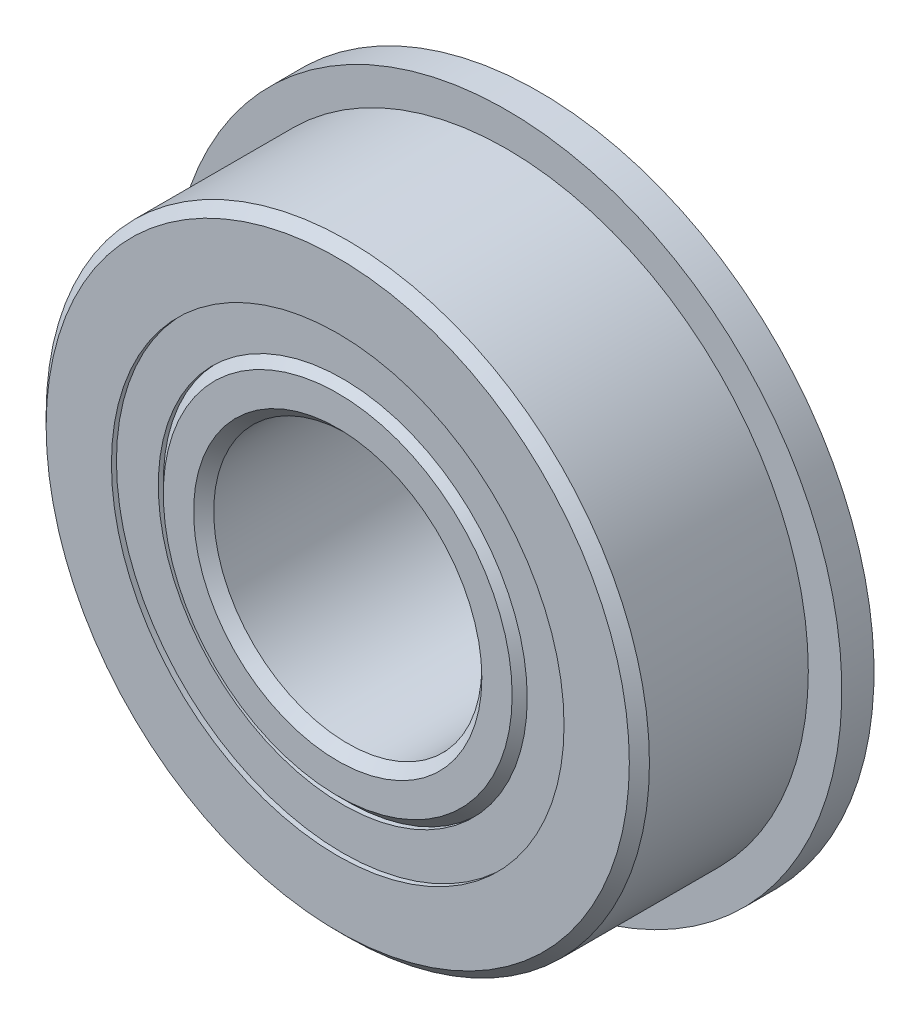
from build123d import *

# Parameters (mm, degrees)
SKETCH6_W          = 1.524
SKETCH6_H          = 5.1562
CIRPATTERN1_COUNT  = 12
SKETCH5_W          = 2.743836812
SKETCH5_H          = 1.9812
CUT_EXTRUDE1_DEPTH = 0.00254


with BuildPart() as part:
    # Sketch1 → Revolve1 (revolve)
    with BuildSketch(Plane(origin=(0, 0, 0), x_dir=(0, 0, -1), z_dir=(1, 0, 0))):
        with BuildLine():
            Line((4.28625, 14.2875), (-4.28625, 14.2875))
            Line((-4.28625, 14.2875), (-4.7625, 13.81125))
            Line((-4.7625, 13.81125), (-4.7625, 10.7188))
            Line((-4.7625, 10.7188), (-2.347405282, 10.7188))
            ThreePointArc((-2.347405282, 10.7188), (0, 12.7), (2.347405282, 10.7188))
            Line((2.347405282, 10.7188), (4.7625, 10.7188))
            Line((4.7625, 10.7188), (4.7625, 13.81125))
            Line((4.7625, 13.81125), (4.28625, 14.2875))
        make_face()
    revolve(axis=Axis((0, 0, 4.7625), (0, 0, -1)))

    # Sketch6 → Revolve6 (revolve)
    with BuildSketch(Plane(origin=(0, 0, 0), x_dir=(0, 0, -1), z_dir=(1, 0, 0))):
        with Locations((4.0005, 13.2969)):
            Rectangle(SKETCH6_W, SKETCH6_H)
    revolve(axis=Axis((0, 0, -4.7625), (0, 0, 1)))

    # Sketch7 → Cut-Extrude1 (cut)
    with BuildSketch(Plane(origin=(0, 0, -4.7625), x_dir=(-1, 0, 0), z_dir=(0, 0, -1))):
        with BuildLine():
            ThreePointArc((-9.493299855, 12.723713407), (-9.643749817, 12.610064015), (-9.792839353, 12.494635745))
            Line((-9.792839353, 12.494635745), (-6.612125131, 8.436378055))
            ThreePointArc((-6.612125131, 8.436378055), (-6.462690611, 8.551391905), (-6.311255911, 8.66375913))
            Line((-6.311255911, 8.66375913), (-9.493299855, 12.723713407))
        make_face()
    extrude(amount=-CUT_EXTRUDE1_DEPTH, mode=Mode.SUBTRACT)


with BuildPart() as body_2:
    # Sketch3 → Revolve3 (revolve)
    with BuildSketch(Plane(origin=(0, 0, 0), x_dir=(0, 0, -1), z_dir=(1, 0, 0))):
        with BuildLine():
            Line((-4.7625, 6.82625), (-4.7625, 8.26135))
            Line((-4.7625, 8.26135), (-4.28625, 8.7376))
            Line((-4.28625, 8.7376), (-1.780538188, 8.7376))
            ThreePointArc((-1.780538188, 8.7376), (0, 7.9375), (1.780538188, 8.7376))
            Line((1.780538188, 8.7376), (5.88645, 8.7376))
            Line((5.88645, 8.7376), (6.3627, 8.26135))
            Line((6.3627, 8.26135), (6.3627, 6.82625))
            Line((6.3627, 6.82625), (5.88645, 6.35))
            Line((5.88645, 6.35), (-4.28625, 6.35))
            Line((-4.28625, 6.35), (-4.7625, 6.82625))
        make_face()
    revolve(axis=Axis((0, 0, 4.7625), (0, 0, -1)))


with BuildPart() as body_3:
    # Sketch4 → Revolve4 (revolve)
    with BuildSketch(Plane(origin=(0, 0, 0), x_dir=(0, 0, -1), z_dir=(1, 0, 0))):
        with BuildLine():
            Line((-2.38125, 10.31875), (2.38125, 10.31875))
            ThreePointArc((2.38125, 10.31875), (0, 12.7), (-2.38125, 10.31875))
        make_face()
    revolve(axis=Axis((0, 10.31875, 2.38125), (0, 0, -1)))


with BuildPart() as cirpattern1_1:
    # CirPattern1: pattern copy
    add(body_3.part.rotate(Axis((0, 0, -4.7625), (0, 0, 1)), 1 * 360 / CIRPATTERN1_COUNT))


with BuildPart() as cirpattern1_2:
    # CirPattern1: pattern copy
    add(body_3.part.rotate(Axis((0, 0, -4.7625), (0, 0, 1)), 2 * 360 / CIRPATTERN1_COUNT))


with BuildPart() as cirpattern1_3:
    # CirPattern1: pattern copy
    add(body_3.part.rotate(Axis((0, 0, -4.7625), (0, 0, 1)), 3 * 360 / CIRPATTERN1_COUNT))


with BuildPart() as cirpattern1_4:
    # CirPattern1: pattern copy
    add(body_3.part.rotate(Axis((0, 0, -4.7625), (0, 0, 1)), 4 * 360 / CIRPATTERN1_COUNT))


with BuildPart() as cirpattern1_5:
    # CirPattern1: pattern copy
    add(body_3.part.rotate(Axis((0, 0, -4.7625), (0, 0, 1)), 5 * 360 / CIRPATTERN1_COUNT))


with BuildPart() as cirpattern1_6:
    # CirPattern1: pattern copy
    add(body_3.part.rotate(Axis((0, 0, -4.7625), (0, 0, 1)), 6 * 360 / CIRPATTERN1_COUNT))


with BuildPart() as cirpattern1_7:
    # CirPattern1: pattern copy
    add(body_3.part.rotate(Axis((0, 0, -4.7625), (0, 0, 1)), 7 * 360 / CIRPATTERN1_COUNT))


with BuildPart() as cirpattern1_8:
    # CirPattern1: pattern copy
    add(body_3.part.rotate(Axis((0, 0, -4.7625), (0, 0, 1)), 8 * 360 / CIRPATTERN1_COUNT))


with BuildPart() as cirpattern1_9:
    # CirPattern1: pattern copy
    add(body_3.part.rotate(Axis((0, 0, -4.7625), (0, 0, 1)), 9 * 360 / CIRPATTERN1_COUNT))


with BuildPart() as cirpattern1_10:
    # CirPattern1: pattern copy
    add(body_3.part.rotate(Axis((0, 0, -4.7625), (0, 0, 1)), 10 * 360 / CIRPATTERN1_COUNT))


with BuildPart() as cirpattern1_11:
    # CirPattern1: pattern copy
    add(body_3.part.rotate(Axis((0, 0, -4.7625), (0, 0, 1)), 11 * 360 / CIRPATTERN1_COUNT))


with BuildPart() as body_15:
    # Sketch5 → Revolve5 (revolve)
    with BuildSketch(Plane(origin=(0, 0, 0), x_dir=(0, 0, -1), z_dir=(1, 0, 0))):
        with Locations((-3.152456594, 9.7282)):
            Rectangle(SKETCH5_W, SKETCH5_H)
        with Locations((3.152456594, 9.7282)):
            Rectangle(SKETCH5_W, SKETCH5_H)
    revolve(axis=Axis((0, 0, 4.7625), (0, 0, -1)))


solid = Compound([part.part, body_2.part, body_3.part, cirpattern1_1.part, cirpattern1_2.part, cirpattern1_3.part, cirpattern1_4.part, cirpattern1_5.part, cirpattern1_6.part, cirpattern1_7.part, cirpattern1_8.part, cirpattern1_9.part, cirpattern1_10.part, cirpattern1_11.part, body_15.part])
